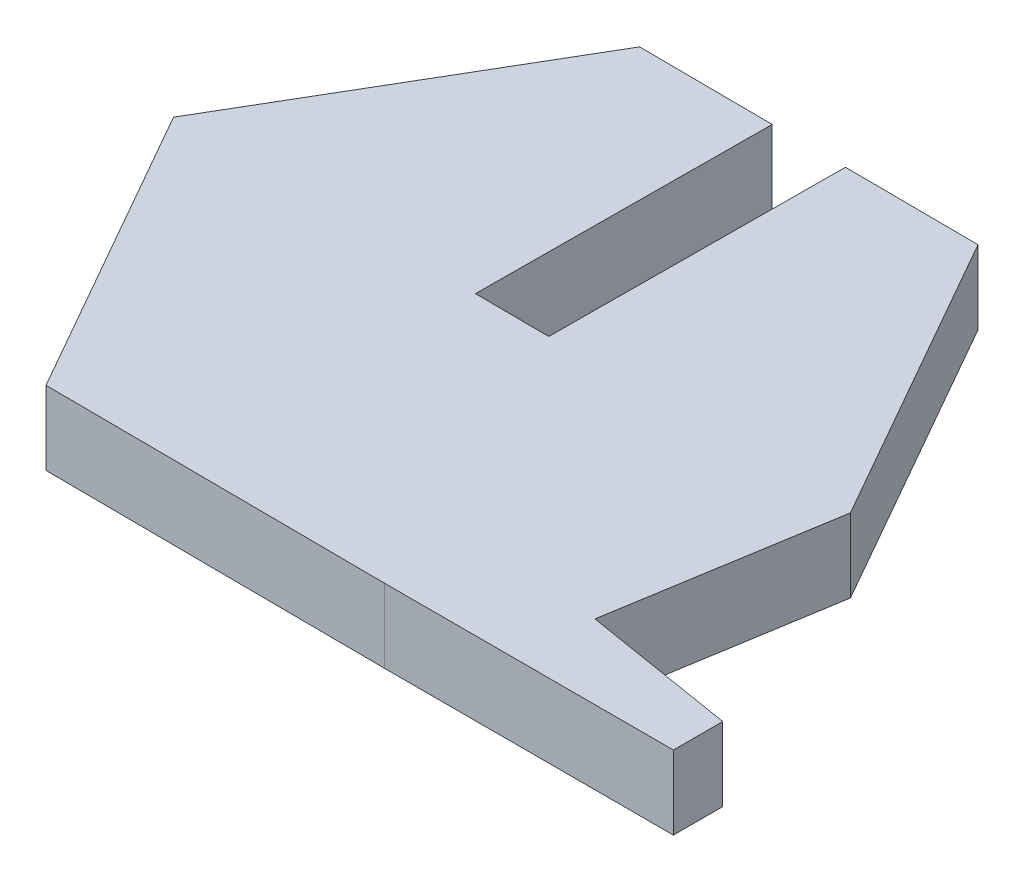
from build123d import *

# Parameters (mm, degrees)
BOSS_EXTRUDE1_DEPTH = 2.5
SKETCH8_W           = 2.5
SKETCH8_H           = 2.5
CUT_EXTRUDE1_DEPTH  = 10


with BuildPart() as part:
    # Sketch1 → Boss-Extrude1 (new body)
    with BuildSketch(Plane(origin=(0, 0, 0), x_dir=(1, 0, 0), z_dir=(0, 1, 0))):
        Polygon((11.546779359, -0.072247979), (10.329867567, -7.516448352), (15.508241902, -8.362963017), (15.508241902, -10.035928246), (5.710821094, -10.035928246), (-5.835958265, -9.963680267), (-11.546779359, 0.072247979), (-5.710821094, 10.035928246), (5.835958265, 9.963680267), align=None)
    extrude(amount=BOSS_EXTRUDE1_DEPTH)

    # Sketch8 → Cut-Extrude1 (cut)
    with BuildSketch(Plane(origin=(0.062568585, 0, -9.999804257), x_dir=(-0.999980426, 0, -0.006256859), z_dir=(0.006256859, 0, -0.999980426))):
        with Locations((-0.002994616, 1.25)):
            Rectangle(SKETCH8_W, SKETCH8_H)
    extrude(amount=-CUT_EXTRUDE1_DEPTH, mode=Mode.SUBTRACT)


solid = part.part
